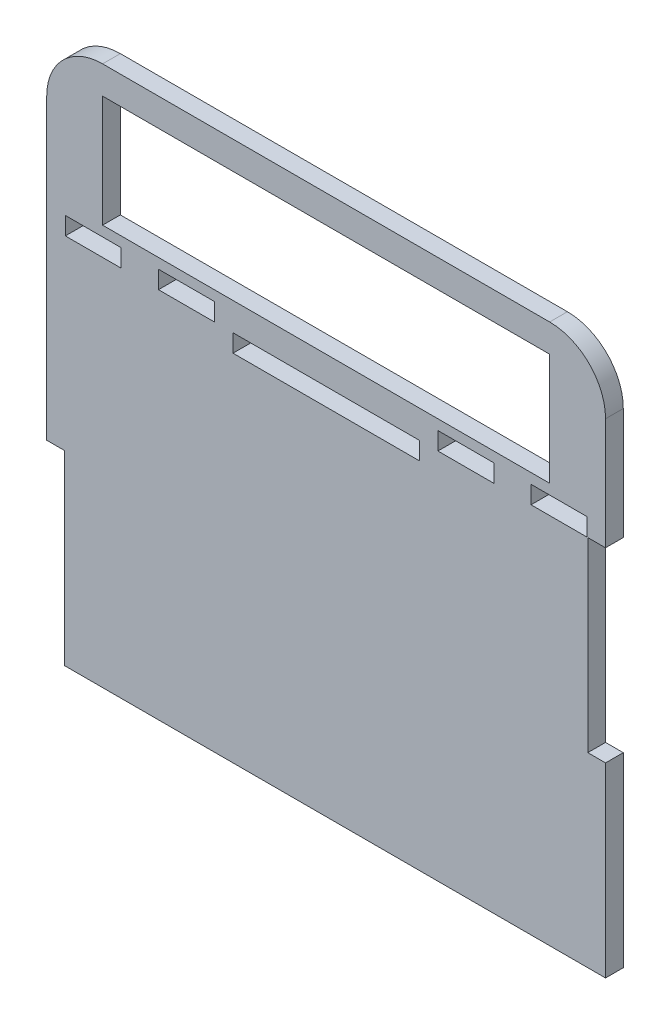
from build123d import *

# Parameters (mm, degrees)
SKETCH1_W           = 33.333333334
SKETCH1_H           = 3.175
SKETCH1_W_2         = 80
SKETCH1_H_2         = 20
BOSS_EXTRUDE1_DEPTH = 3.175
FILLET1_R           = 10
SKETCH2_W           = 10
SKETCH2_H           = 3.175
CUT_EXTRUDE1_DEPTH  = 3.175


with BuildPart() as part:
    # Sketch1 → Boss-Extrude1 (new body)
    with BuildSketch(Plane.XY):
        Polygon((-50, 16.666666667), (-50, 50), (-50, 80), (50, 80), (50, 50), (46.825, 50), (46.825, 16.666666667), (50, 16.666666667), (50, -16.666666667), (46.825, -16.666666667), (-46.825, -16.666666667), (-46.825, 16.666666667), align=None)
        with Locations((0, 48.4125)):
            Rectangle(SKETCH1_W, SKETCH1_H, mode=Mode.SUBTRACT)
        with Locations((0, 65)):
            Rectangle(SKETCH1_W_2, SKETCH1_H_2, mode=Mode.SUBTRACT)
    extrude(amount=BOSS_EXTRUDE1_DEPTH)

    # Fillet1
    fillet1_edges = [part.edges().sort_by_distance(p)[0] for p in [
        (-50, 80, 1.5875),
        (50, 80, 1.5875),
    ]]
    fillet(fillet1_edges, radius=FILLET1_R)

    # Sketch2 → Cut-Extrude1 (cut)
    with BuildSketch(Plane.XY.offset(3.175)):
        with Locations((25, 51.5875)):
            Rectangle(SKETCH2_W, SKETCH2_H)
        with Locations((-41.666666667, 51.5875)):
            Rectangle(SKETCH2_W, SKETCH2_H)
        with Locations((-25, 51.5875)):
            Rectangle(SKETCH2_W, SKETCH2_H)
        with Locations((41.666666667, 51.5875)):
            Rectangle(SKETCH2_W, SKETCH2_H)
    extrude(amount=-CUT_EXTRUDE1_DEPTH, mode=Mode.SUBTRACT)


solid = part.part
